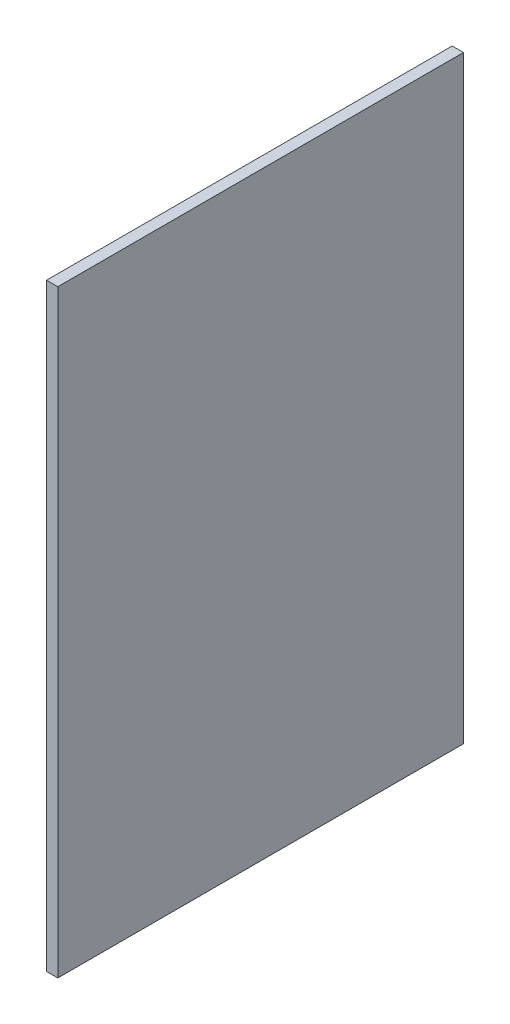
from build123d import *

# Parameters (mm, degrees)
SKETCH1_W      = 576
SKETCH1_H      = 850
EXTRUDE1_DEPTH = 16


with BuildPart() as part:
    # Sketch1 → Extrude1 (new body)
    with BuildSketch(Plane(origin=(0, 0, 0), x_dir=(0, 0, -1), z_dir=(1, 0, 0))):
        with Locations((288, 425)):
            Rectangle(SKETCH1_W, SKETCH1_H)
    extrude(amount=-EXTRUDE1_DEPTH)


solid = part.part
